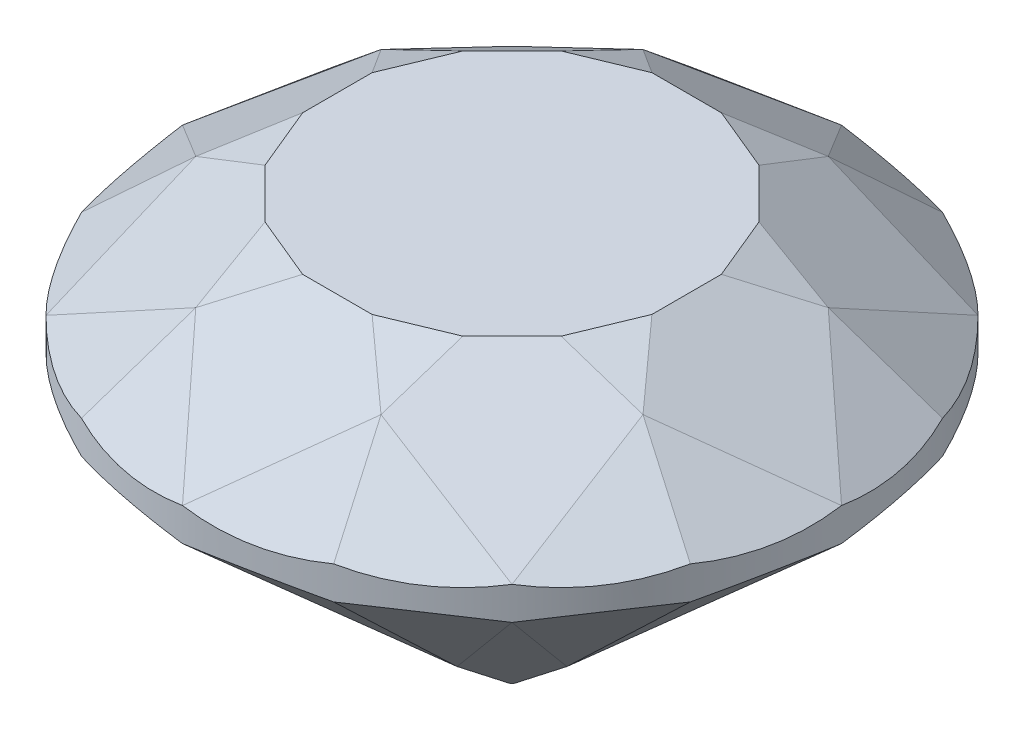
from build123d import *

# Parameters (mm, degrees)
ESQUISSE1_R                  = 5
BOSS_EXTRU_4_DEPTH           = 0.5
BOSS_EXTRU_5_DEPTH           = 4.32
BOSS_EXTRU_6_DEPTH           = 1.6
ENL_V_MAT_EXTRU_1_DEPTH      = 6
R_P_TITION_CIRCULAIRE1_COUNT = 8
ENL_V_MAT_EXTRU_4_DEPTH      = 7.935199227
R_P_TITION_CIRCULAIRE2_COUNT = 16
ENL_V_MAT_EXTRU_5_DEPTH      = 7.532814824
R_P_TITION_CIRCULAIRE3_COUNT = 8


with BuildPart() as part:
    # Esquisse1 → Boss.-Extru.4 (new body)
    with BuildSketch(Plane(origin=(0, 0, 0), x_dir=(1, 0, 0), z_dir=(0, 1, 0))):
        with Locations(Location((0, 0, 0), (0, 0, 270))):  # turned: the seam where the file's is
            Circle(ESQUISSE1_R)
    extrude(amount=BOSS_EXTRU_4_DEPTH)

    # Esquisse1_4 → Boss.-Extru.5 (add)
    with BuildSketch(Plane(origin=(0, 0, 0), x_dir=(1, 0, 0), z_dir=(0, 1, 0))):
        Polygon((2.832272487, -4.238795325), (4.238795325, -2.832272487), (5, -0.994561837), (5, 0.994561837), (4.238795325, 2.832272487), (2.832272487, 4.238795325), (0.994561837, 5), (-0.994561837, 5), (-2.832272487, 4.238795325), (-4.238795325, 2.832272487), (-5, 0.994561837), (-5, -0.994561837), (-4.238795325, -2.832272487), (-2.832272487, -4.238795325), (-0.994561837, -5), (0.994561837, -5), align=None)
    extrude(amount=-BOSS_EXTRU_5_DEPTH)

    # Esquisse11 → Boss.-Extru.6 (add)
    with BuildSketch(Plane(origin=(0, 0.5, 0), x_dir=(1, 0, 0), z_dir=(0, 1, 0))):
        Polygon((-0.994561837, 5), (-2.832272487, 4.238795325), (-4.238795325, 2.832272487), (-5, 0.994561837), (-5, -0.994561837), (-4.238795325, -2.832272487), (-2.832272487, -4.238795325), (-0.994561837, -5), (0.994561837, -5), (2.832272487, -4.238795325), (4.238795325, -2.832272487), (5, -0.994561837), (5, 0.994561837), (4.238795325, 2.832272487), (2.832272487, 4.238795325), (0.994561837, 5), align=None)
    extrude(amount=BOSS_EXTRU_6_DEPTH)

    # Esquisse7 → Enl_v. mat.-Extru.1 (cut, symmetric)
    with BuildSketch(Plane.XY):
        Polygon((-7, 0), (-7, -4.32), (-0.030408481, -4.32), (-5, 0), (-5, 0.5), (-2.65, 2.1), (-7, 2.1), align=None)
    enl_v_mat_extru_1 = extrude(amount=ENL_V_MAT_EXTRU_1_DEPTH, both=True, mode=Mode.SUBTRACT)

    # R_p_tition circulaire1: Enl_v. mat.-Extru.1 ×8 about axis
    r_p_tition_circulaire1_axis = Axis((0, 0, 0), (0, 1, 0))
    for i in range(1, R_P_TITION_CIRCULAIRE1_COUNT):
        add(enl_v_mat_extru_1.rotate(r_p_tition_circulaire1_axis, i * 360 / R_P_TITION_CIRCULAIRE1_COUNT), mode=Mode.SUBTRACT)

    # Esquisse10 → Enl_v. mat.-Extru.4 (cut, symmetric)
    with BuildSketch(Plane(origin=(0, 0, 0), x_dir=(-0.831469612, 0, -0.555570233), z_dir=(0.555570233, 0, -0.831469612))):
        Polygon((5.903926402, 0), (5.903926402, -4.86712571), (-0.407609261, -4.86712571), (4.903926402, 0), (5.221818983, 0.232853051), (4.903926402, 0.5), (3, 2.1), (5.903926402, 2.1), align=None)
    enl_v_mat_extru_4 = extrude(amount=ENL_V_MAT_EXTRU_4_DEPTH, both=True, mode=Mode.SUBTRACT)

    # R_p_tition circulaire2: Enl_v. mat.-Extru.4 ×16 about axis
    r_p_tition_circulaire2_axis = Axis((0, 0, 0), (0, 1, 0))
    for i in range(1, R_P_TITION_CIRCULAIRE2_COUNT):
        add(enl_v_mat_extru_4.rotate(r_p_tition_circulaire2_axis, i * 360 / R_P_TITION_CIRCULAIRE2_COUNT), mode=Mode.SUBTRACT)

    # Esquisse13 → Enl_v. mat.-Extru.5 (cut, symmetric)
    with BuildSketch(Plane(origin=(0, 0, 0), x_dir=(-0.923879533, 0, -0.382683432), z_dir=(0.382683432, 0, -0.923879533))):
        Polygon((3.672450086, 1.594194745), (2.65, 2.1), (3.922671549, 2.1), align=None)
        Polygon((-3.922671549, 2.1), (-3.672450086, 1.594194745), (-2.65, 2.1), align=None)
    enl_v_mat_extru_5 = extrude(amount=ENL_V_MAT_EXTRU_5_DEPTH, both=True, mode=Mode.SUBTRACT)

    # R_p_tition circulaire3: Enl_v. mat.-Extru.5 ×8 about axis
    r_p_tition_circulaire3_axis = Axis((0, 0, 0), (0, 1, 0))
    for i in range(1, R_P_TITION_CIRCULAIRE3_COUNT):
        add(enl_v_mat_extru_5.rotate(r_p_tition_circulaire3_axis, i * 360 / R_P_TITION_CIRCULAIRE3_COUNT), mode=Mode.SUBTRACT)


solid = part.part
